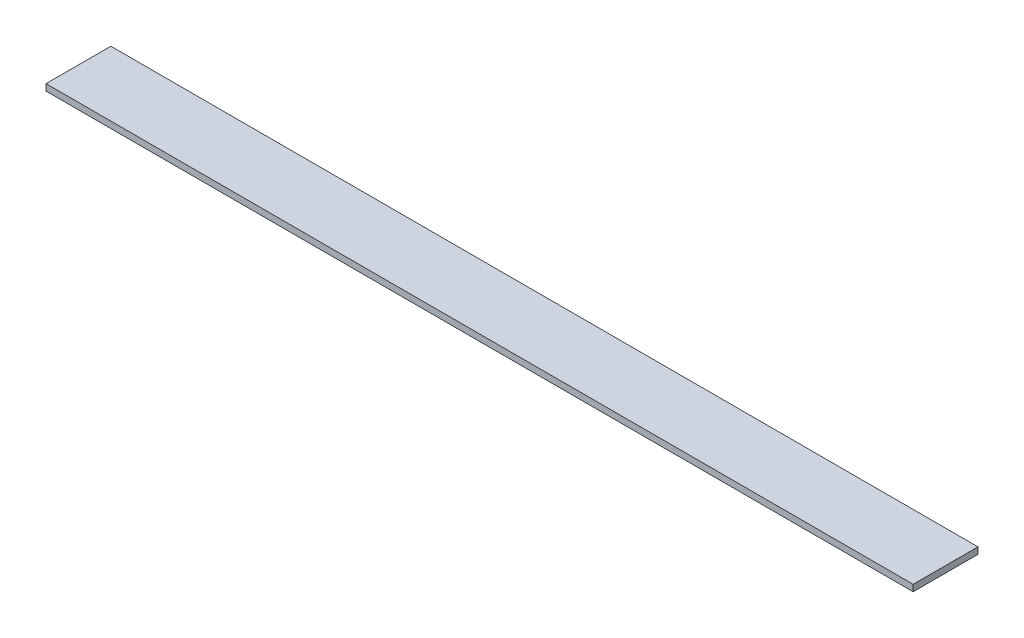
from build123d import *

# Parameters (mm, degrees)
SKETCH_1_W      = 80
SKETCH_1_H      = 8
EXTRUDE_1_DEPTH = 1070


with BuildPart() as part:
    # Эскиз1 → Бобышка-Вытянуть1 (new body)
    with BuildSketch(Plane(origin=(0, 0, 0), x_dir=(0, 0, -1), z_dir=(1, 0, 0))):
        with Locations((0, 4)):
            Rectangle(SKETCH_1_W, SKETCH_1_H)
    extrude(amount=EXTRUDE_1_DEPTH)


solid = part.part
